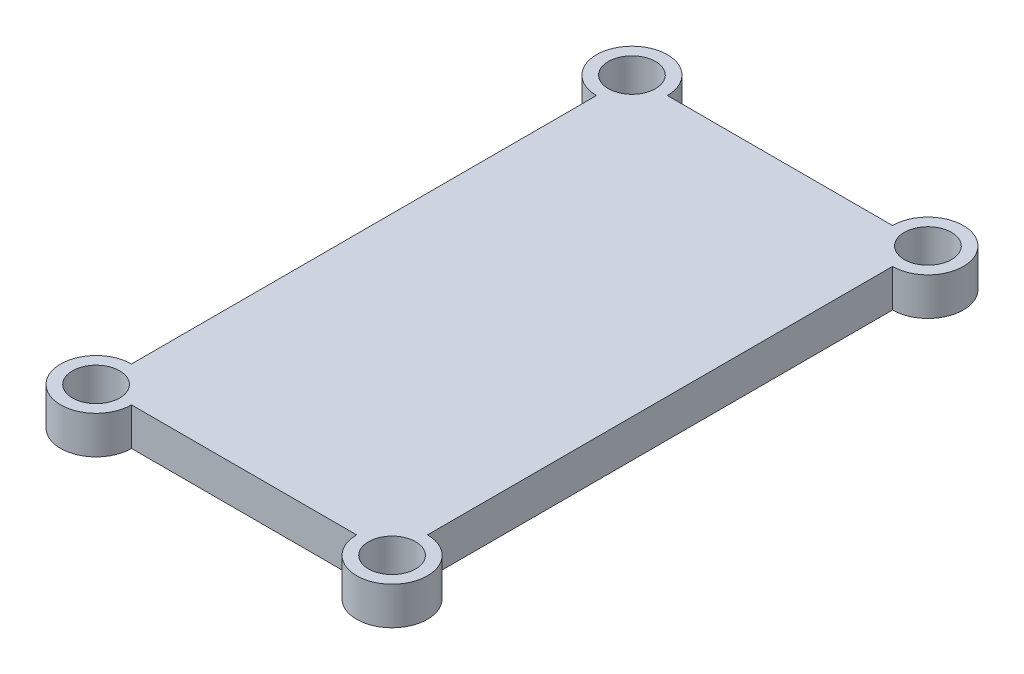
from build123d import *

# Parameters (mm, degrees)
SKETCH1_W           = 62.7
SKETCH1_H           = 113.5
BOSS_EXTRUDE1_DEPTH = 8
SKETCH2_R           = 7.5
BOSS_EXTRUDE2_DEPTH = 8
SKETCH3_R           = 5
CUT_EXTRUDE1_DEPTH  = 8


with BuildPart() as part:
    # Sketch1 → Boss-Extrude1 (new body)
    with BuildSketch(Plane(origin=(-3.563e-06, 1641.987881811, -1.519e-06), x_dir=(0.999999999, 2e-09, 3.7953e-05), z_dir=(-2e-09, 1, -1e-09))):
        with Locations((574.61782777, -1423.325985679)):
            Rectangle(SKETCH1_W, SKETCH1_H)
    extrude(amount=BOSS_EXTRUDE1_DEPTH)

    # Sketch2 → Boss-Extrude2 (add)
    with BuildSketch(Plane(origin=(-3.563e-06, 1641.987881811, -1.519e-06), x_dir=(0.999999999, 2e-09, 3.7953e-05), z_dir=(2e-09, -1, 1e-09))):
        with Locations((543.26782777, 1366.575985679)):
            Circle(SKETCH2_R)
        with Locations((605.96782777, 1366.575985679)):
            Circle(SKETCH2_R)
        with Locations((605.96782777, 1480.075985679)):
            Circle(SKETCH2_R)
        with Locations((543.26782777, 1480.075985679)):
            Circle(SKETCH2_R)
    extrude(amount=-BOSS_EXTRUDE2_DEPTH)

    # Sketch3 → Cut-Extrude1 (cut)
    with BuildSketch(Plane(origin=(-3.563e-06, 1641.987881811, -1.519e-06), x_dir=(0.999999999, 2e-09, 3.7953e-05), z_dir=(2e-09, -1, 1e-09))):
        with Locations((543.26782777, 1480.075985679)):
            Circle(SKETCH3_R)
        with Locations((605.96782777, 1480.075985679)):
            Circle(SKETCH3_R)
        with Locations((605.96782777, 1366.575985679)):
            Circle(SKETCH3_R)
        with Locations((543.26782777, 1366.575985679)):
            Circle(SKETCH3_R)
    extrude(amount=-CUT_EXTRUDE1_DEPTH, mode=Mode.SUBTRACT)


solid = part.part
